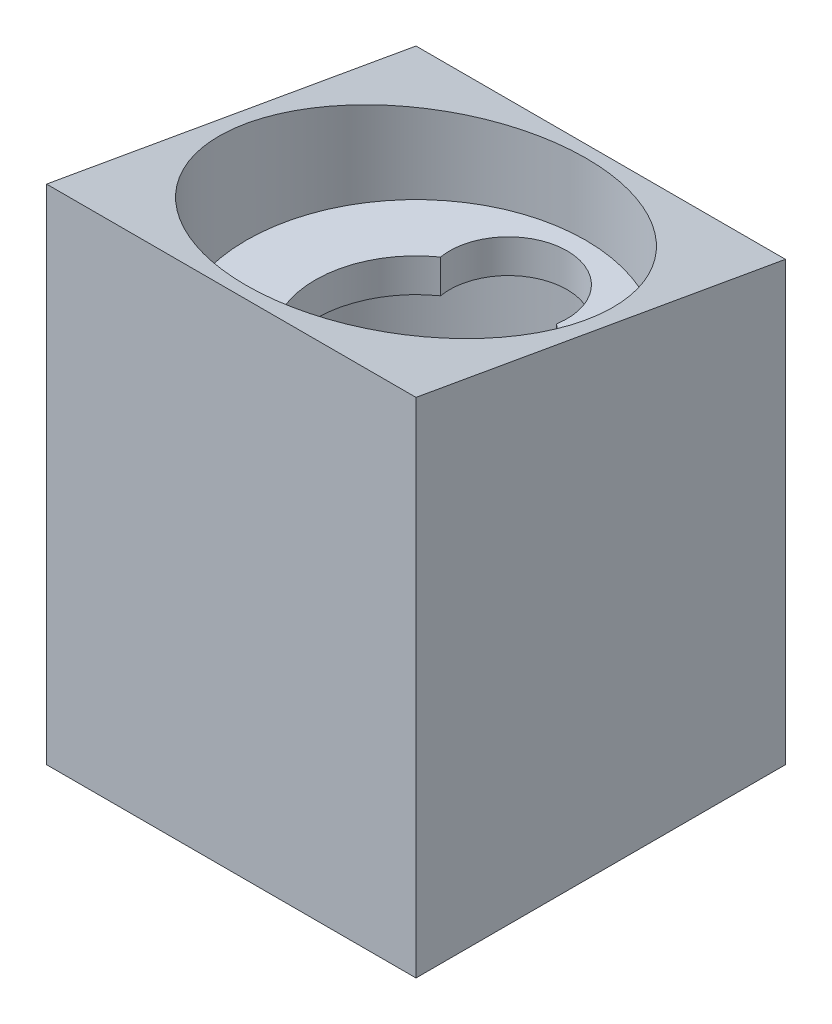
from build123d import *

# Parameters (mm, degrees)
SKETCH2_R                = 10.1
BOSS_EXTRUDE1_DEPTH      = 2
SKETCH3_W                = 22
SKETCH3_H                = 22
SKETCH3_R                = 10.125
BOSS_EXTRUDE2_DEPTH      = 8
BOSS_EXTRUDE2_DEPTH_BACK = 22
SKETCH5_R                = 0.985
CUT_EXTRUDE2_DEPTH       = 6
CUT_EXTRUDE3_DEPTH       = 23


with BuildPart() as part:
    # Sketch2 → Boss-Extrude1 (new body)
    with BuildSketch(Plane(origin=(0, 0, 0), x_dir=(1, 0, 0), z_dir=(0, 1, 0))):
        Circle(SKETCH2_R)
        with BuildLine():
            ThreePointArc((-3.449757447, 4.909090909), (0, 9), (3.449757447, 4.909090909))
            ThreePointArc((3.449757447, 4.909090909), (0, -6), (-3.449757447, 4.909090909))
        make_face(mode=Mode.SUBTRACT)
    extrude(amount=BOSS_EXTRUDE1_DEPTH)


with BuildPart() as body_2:
    # Sketch3 → Boss-Extrude2 (new body, two sides)
    with BuildSketch(Plane(origin=(0, 2, 0), x_dir=(1, 0, 0), z_dir=(0, 1, 0))) as boss_extrude2_sk:
        Rectangle(SKETCH3_W, SKETCH3_H)
        Circle(SKETCH3_R, mode=Mode.SUBTRACT)
    extrude(amount=BOSS_EXTRUDE2_DEPTH)
    extrude(boss_extrude2_sk.sketch, amount=-BOSS_EXTRUDE2_DEPTH_BACK)

    # Sketch5 → Cut-Extrude2 (cut)
    with BuildSketch(Plane(origin=(0, -20, 0), x_dir=(-1, 0, 0), z_dir=(0, -1, 0))):
        with Locations((9.25, -9)):
            Circle(SKETCH5_R)
        with Locations((9.25, 9)):
            Circle(SKETCH5_R)
        with Locations((-9.25, 9)):
            Circle(SKETCH5_R)
        with Locations((-9.25, -9)):
            Circle(SKETCH5_R)
    extrude(amount=-CUT_EXTRUDE2_DEPTH, mode=Mode.SUBTRACT)

    # Sketch6 → Cut-Extrude3 (cut, through all)
    with BuildSketch(Plane(origin=(11, 0, 0), x_dir=(0, 0, -1), z_dir=(1, 0, 0))):
        Polygon((11, 6.06291723), (-11, 9.942110806), (-11, 10), (11, 10), align=None)
    extrude(amount=-CUT_EXTRUDE3_DEPTH, mode=Mode.SUBTRACT)


solid = Compound([part.part, body_2.part])
